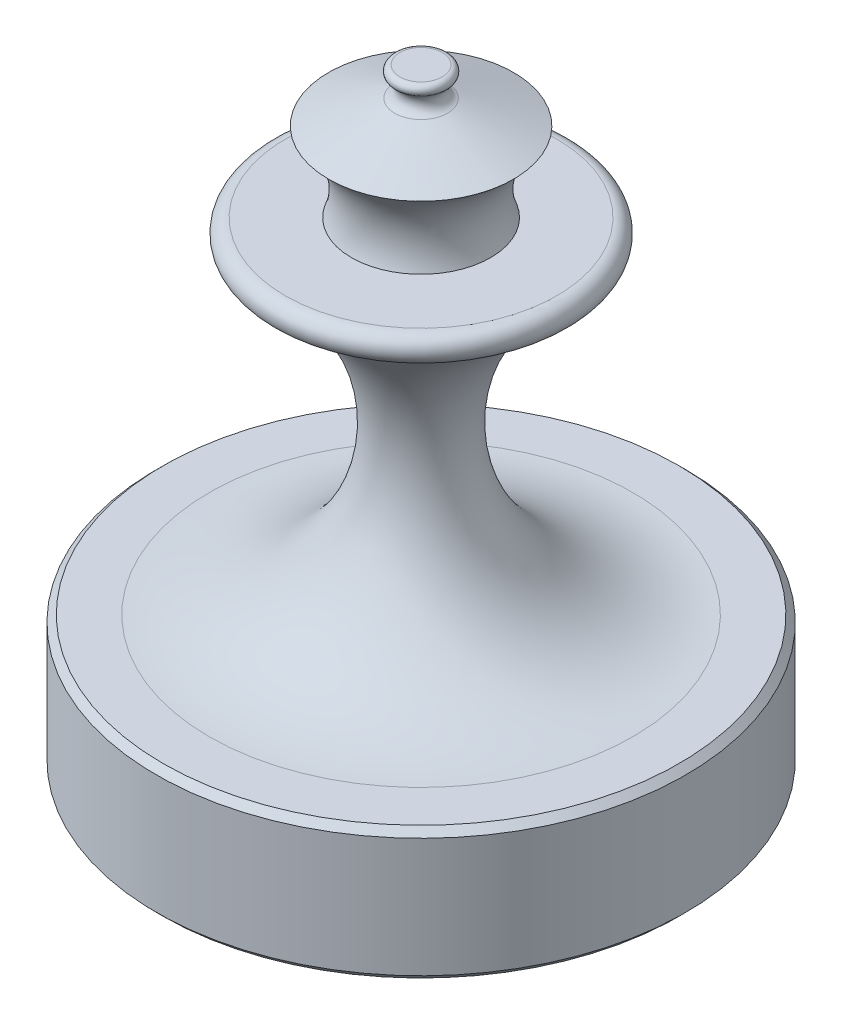
from build123d import *

# Parameters (mm, degrees)
ESQUISSE2_R      = 100
EXTRUSION1_DEPTH = 50
CHANFREIN1_SIZE  = 2.5


with BuildPart() as part:
    # Esquisse1 → Révolution2 (revolve)
    with BuildSketch(Plane.XY):
        with BuildLine():
            Line((-51.309907157, 130), (-26.309907157, 130))
            ThreePointArc((-26.309907157, 130), (-25.521257356, 146.474713304), (-34.960789483, 160))
            Line((-34.960789483, 160), (-9.960789483, 169.076905642))
            ThreePointArc((-9.960789483, 169.076905642), (-7.357570715, 172.370411723), (-9.139785961, 176.171416732))
            ThreePointArc((-9.139785961, 176.171416732), (-9.997320823, 178.510659869), (-8, 180))
            Line((-8, 180), (0, 180))
            Line((0, 180), (0, 0))
            Line((0, 0), (-80, 0))
            ThreePointArc((-80, 0), (-18.451459014, 49.446261503), (-53.471688698, 120.204576824))
            ThreePointArc((-53.471688698, 120.204576824), (-56.325473292, 125.970643808), (-51.309907157, 130))
        make_face()
    revolve(axis=Axis((0, 180, 0), (0, -1, 0)))

    # Esquisse2 → Extrusion1 (add)
    with BuildSketch(Plane.XZ):
        Circle(ESQUISSE2_R)
    extrude(amount=EXTRUSION1_DEPTH)

    # Chanfrein1
    chanfrein1_edges = [part.edges().sort_by_distance(p)[0] for p in [
        (-100, 0, 0),
        (-100, -50, 0),
    ]]
    chamfer(chanfrein1_edges, length=CHANFREIN1_SIZE)


solid = part.part
